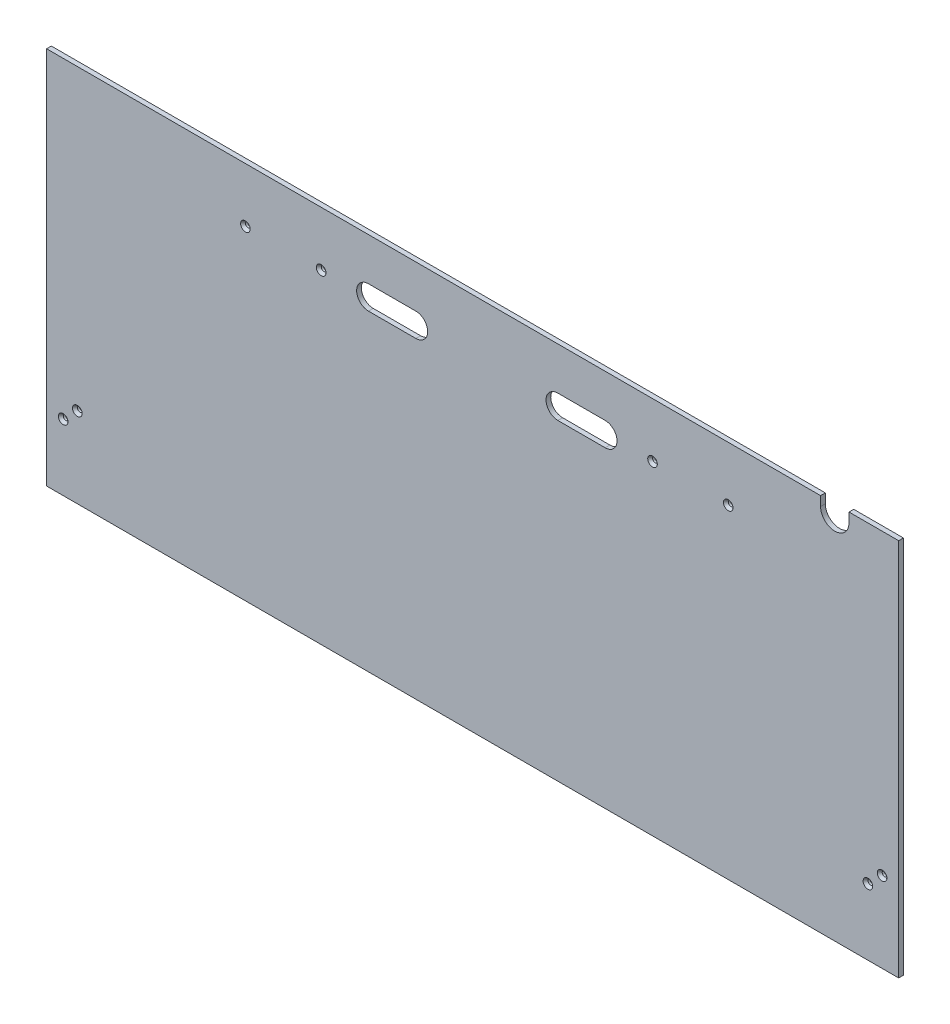
from build123d import *

# Parameters (mm, degrees)
SKETCH1_W                                     = 1143
SKETCH1_H                                     = 508
BOSS_EXTRUDE1_DEPTH                           = 6.35
CUT_EXTRUDE1_DEPTH                            = 7.35
CSK_FOR_1_4_FLAT_HEAD_MACHINE_SCREW1_AT_COUNT = 2
CSK_FOR_1_4_FLAT_HEAD_MACHINE_SCREW1_AT_PITCH = 101.6
CSK_FOR_1_4_FLAT_HEAD_MACHINE_SCREW1_2_COUNT  = 2
CSK_FOR_1_4_FLAT_HEAD_MACHINE_SCREW1_2_PITCH  = 546.1
CSK_FOR_1_4_FLAT_HEAD_MACHINE_SCREW1_3_COUNT  = 2
CSK_FOR_1_4_FLAT_HEAD_MACHINE_SCREW1_3_PITCH  = 647.7
CSK_FOR_1_4_FLAT_HEAD_MACHINE_SCREW1_4_COUNT  = 2
CSK_FOR_1_4_FLAT_HEAD_MACHINE_SCREW1_4_PITCH  = 386.698837922
CSK_FOR_1_4_FLAT_HEAD_MACHINE_SCREW1_5_COUNT  = 2
CSK_FOR_1_4_FLAT_HEAD_MACHINE_SCREW1_5_PITCH  = 393.520725312
CSK_FOR_1_4_FLAT_HEAD_MACHINE_SCREW1_6_COUNT  = 2
CSK_FOR_1_4_FLAT_HEAD_MACHINE_SCREW1_6_PITCH  = 932.358630705
CSK_FOR_1_4_FLAT_HEAD_MACHINE_SCREW1_7_COUNT  = 2
CSK_FOR_1_4_FLAT_HEAD_MACHINE_SCREW1_7_PITCH  = 956.945210683
CUT_EXTRUDE2_DEPTH                            = 7.35


with BuildPart() as part:
    # Sketch1 → Boss-Extrude1 (new body)
    with BuildSketch(Plane.XY):
        with Locations((571.5, 254)):
            Rectangle(SKETCH1_W, SKETCH1_H)
    extrude(amount=BOSS_EXTRUDE1_DEPTH)

    # Sketch2 → Cut-Extrude1 (cut, through all)
    with BuildSketch(Plane.XY.offset(6.35)):
        with BuildLine():
            Line((431.8, 450.85), (495.3, 450.85))
            ThreePointArc((495.3, 450.85), (511.175, 434.975), (495.3, 419.1))
            Line((495.3, 419.1), (431.8, 419.1))
            ThreePointArc((431.8, 419.1), (415.925, 434.975), (431.8, 450.85))
        make_face()
        with BuildLine():
            Line((685.8, 450.85), (749.3, 450.85))
            ThreePointArc((749.3, 450.85), (765.175, 434.975), (749.3, 419.1))
            Line((749.3, 419.1), (685.8, 419.1))
            ThreePointArc((685.8, 419.1), (669.925, 434.975), (685.8, 450.85))
        make_face()
    extrude(amount=-CUT_EXTRUDE1_DEPTH, mode=Mode.SUBTRACT)

    # Sketch5 → CSK for 1/4 Flat Head Machine Screw1 (revolve, cut)
    with BuildSketch(Plane(origin=(914.4, 434.975, 6.35), x_dir=(0, -1, 0), z_dir=(1, 0, 0))):
        Polygon((0, 0), (0, 6.35), (3.3782, 6.35), (3.3782, 3.520932584), (6.4389, 0), align=None)
    csk_for_1_4_flat_head_machine_screw1 = revolve(axis=Axis((914.4, 434.975, 12.7), (0, 0, -1)), mode=Mode.SUBTRACT)

    # CSK for 1/4 Flat Head Machine Screw1 at: CSK for 1/4 Flat Head Machine Screw1 ×2
    with Locations(*[(-i * CSK_FOR_1_4_FLAT_HEAD_MACHINE_SCREW1_AT_PITCH, 0, 0) for i in range(1, CSK_FOR_1_4_FLAT_HEAD_MACHINE_SCREW1_AT_COUNT)]):
        add(csk_for_1_4_flat_head_machine_screw1, mode=Mode.SUBTRACT)

    # CSK for 1_4 Flat Head Machine Screw1 2: CSK for 1/4 Flat Head Machine Screw1 ×2
    with Locations(*[(-i * CSK_FOR_1_4_FLAT_HEAD_MACHINE_SCREW1_2_PITCH, 0, 0) for i in range(1, CSK_FOR_1_4_FLAT_HEAD_MACHINE_SCREW1_2_COUNT)]):
        add(csk_for_1_4_flat_head_machine_screw1, mode=Mode.SUBTRACT)

    # CSK for 1_4 Flat Head Machine Screw1 3: CSK for 1/4 Flat Head Machine Screw1 ×2
    with Locations(*[(-i * CSK_FOR_1_4_FLAT_HEAD_MACHINE_SCREW1_3_PITCH, 0, 0) for i in range(1, CSK_FOR_1_4_FLAT_HEAD_MACHINE_SCREW1_3_COUNT)]):
        add(csk_for_1_4_flat_head_machine_screw1, mode=Mode.SUBTRACT)

    # CSK for 1_4 Flat Head Machine Screw1 4: CSK for 1/4 Flat Head Machine Screw1 ×2
    with Locations(*[Vector(0.533684045, -0.845683948, 0) * (i * CSK_FOR_1_4_FLAT_HEAD_MACHINE_SCREW1_4_PITCH) for i in range(1, CSK_FOR_1_4_FLAT_HEAD_MACHINE_SCREW1_4_COUNT)]):
        add(csk_for_1_4_flat_head_machine_screw1, mode=Mode.SUBTRACT)

    # CSK for 1_4 Flat Head Machine Screw1 5: CSK for 1/4 Flat Head Machine Screw1 ×2
    with Locations(*[Vector(0.476023213, -0.879432715, 0) * (i * CSK_FOR_1_4_FLAT_HEAD_MACHINE_SCREW1_5_PITCH) for i in range(1, CSK_FOR_1_4_FLAT_HEAD_MACHINE_SCREW1_5_COUNT)]):
        add(csk_for_1_4_flat_head_machine_screw1, mode=Mode.SUBTRACT)

    # CSK for 1_4 Flat Head Machine Screw1 6: CSK for 1/4 Flat Head Machine Screw1 ×2
    with Locations(*[Vector(-0.936469049, -0.350750226, 0) * (i * CSK_FOR_1_4_FLAT_HEAD_MACHINE_SCREW1_6_PITCH) for i in range(1, CSK_FOR_1_4_FLAT_HEAD_MACHINE_SCREW1_6_COUNT)]):
        add(csk_for_1_4_flat_head_machine_screw1, mode=Mode.SUBTRACT)

    # CSK for 1_4 Flat Head Machine Screw1 7: CSK for 1/4 Flat Head Machine Screw1 ×2
    with Locations(*[Vector(-0.932315654, -0.361645574, 0) * (i * CSK_FOR_1_4_FLAT_HEAD_MACHINE_SCREW1_7_PITCH) for i in range(1, CSK_FOR_1_4_FLAT_HEAD_MACHINE_SCREW1_7_COUNT)]):
        add(csk_for_1_4_flat_head_machine_screw1, mode=Mode.SUBTRACT)

    # Sketch6 → Cut-Extrude2 (cut, through all)
    with BuildSketch(Plane.XY.offset(6.35)):
        with BuildLine():
            Line((1038.225, 508), (1076.325, 508))
            Line((1076.325, 508), (1076.325, 495.3))
            ThreePointArc((1076.325, 495.3), (1057.275, 476.25), (1038.225, 495.3))
            Line((1038.225, 495.3), (1038.225, 508))
        make_face()
    extrude(amount=-CUT_EXTRUDE2_DEPTH, mode=Mode.SUBTRACT)


solid = part.part
